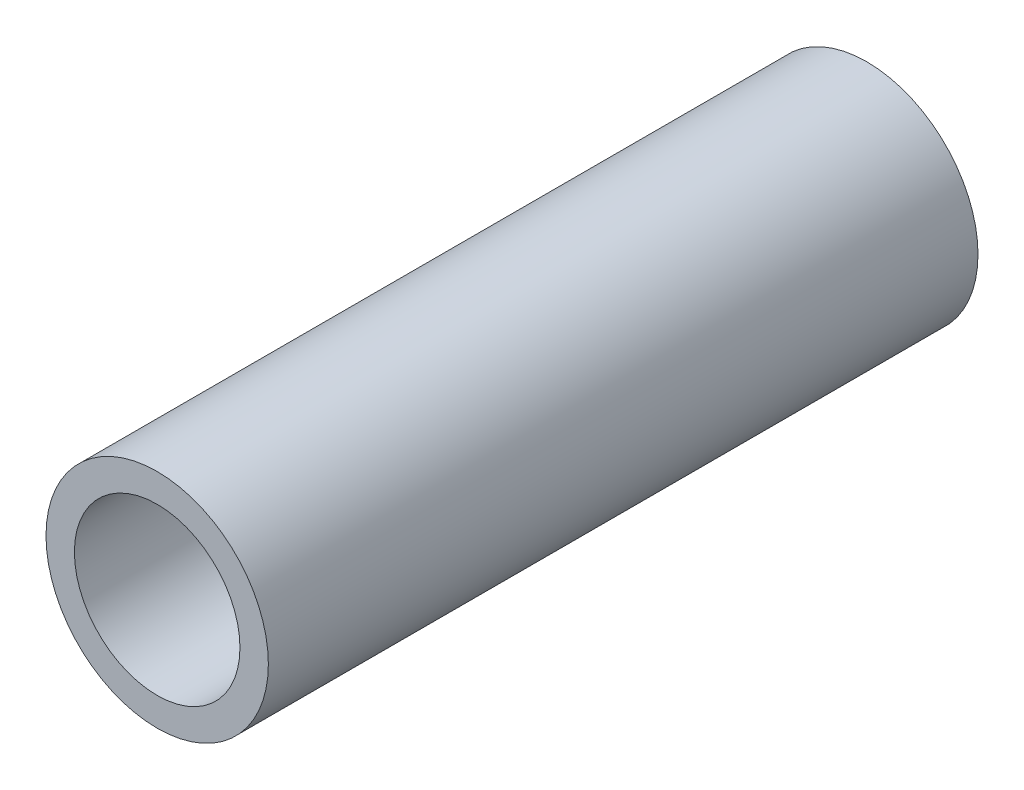
from build123d import *

# Parameters (mm, degrees)
SKETCH1_R           = 5.969
BOSS_EXTRUDE1_DEPTH = 38.1
SKETCH2_R           = 4.445
CUT_EXTRUDE1_DEPTH  = 38.1


with BuildPart() as part:
    # Sketch1 → Boss-Extrude1 (new body)
    with BuildSketch(Plane.XY):
        Circle(SKETCH1_R)
    extrude(amount=BOSS_EXTRUDE1_DEPTH)

    # Sketch2 → Cut-Extrude1 (cut)
    with BuildSketch(Plane.XY.offset(38.1)):
        Circle(SKETCH2_R)
    extrude(amount=-CUT_EXTRUDE1_DEPTH, mode=Mode.SUBTRACT)


solid = part.part
